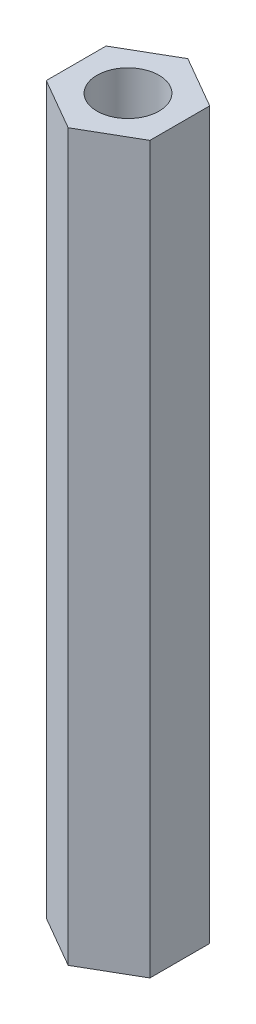
from build123d import *

# Parameters (mm, degrees)
SKETCH1_R           = 1.905
BOSS_EXTRUDE1_DEPTH = 44.45


with BuildPart() as part:
    # Sketch1 → Boss-Extrude1 (new body)
    with BuildSketch(Plane(origin=(0, 0, 0), x_dir=(1, 0, 0), z_dir=(0, 1, 0))):
        Polygon((0, -3.666174209), (3.175, -1.833087105), (3.175, 1.833087105), (0, 3.666174209), (-3.175, 1.833087105), (-3.175, -1.833087105), align=None)
        Circle(SKETCH1_R, mode=Mode.SUBTRACT)
    extrude(amount=BOSS_EXTRUDE1_DEPTH)


solid = part.part
